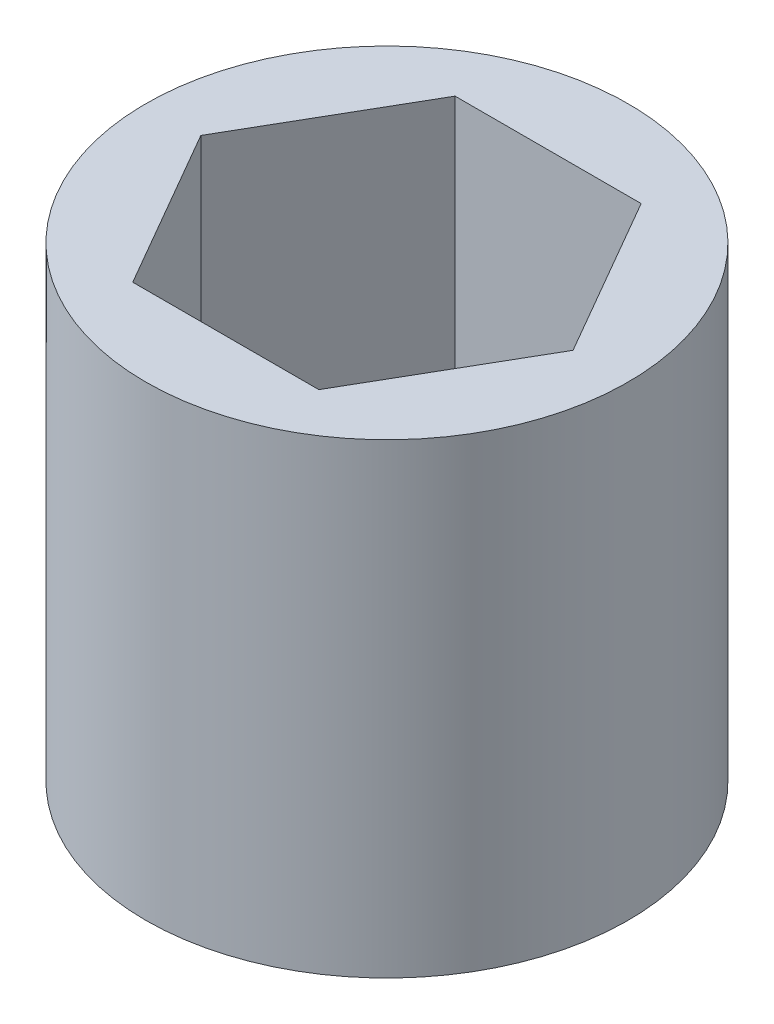
from build123d import *

# Parameters (mm, degrees)
SKETCH1_R           = 7.5
BOSS_EXTRUDE1_DEPTH = 7.25


with BuildPart() as part:
    # Sketch1 → Boss-Extrude1 (new, symmetric)
    with BuildSketch(Plane(origin=(0, 0, 0), x_dir=(1, 0, 0), z_dir=(0, 1, 0))):
        Circle(SKETCH1_R)
        Polygon((-2.893968224, -5.0125), (2.893968224, -5.0125), (5.787936449, 0), (2.893968224, 5.0125), (-2.893968224, 5.0125), (-5.787936449, 0), align=None, mode=Mode.SUBTRACT)
    extrude(amount=BOSS_EXTRUDE1_DEPTH, both=True)


solid = part.part
